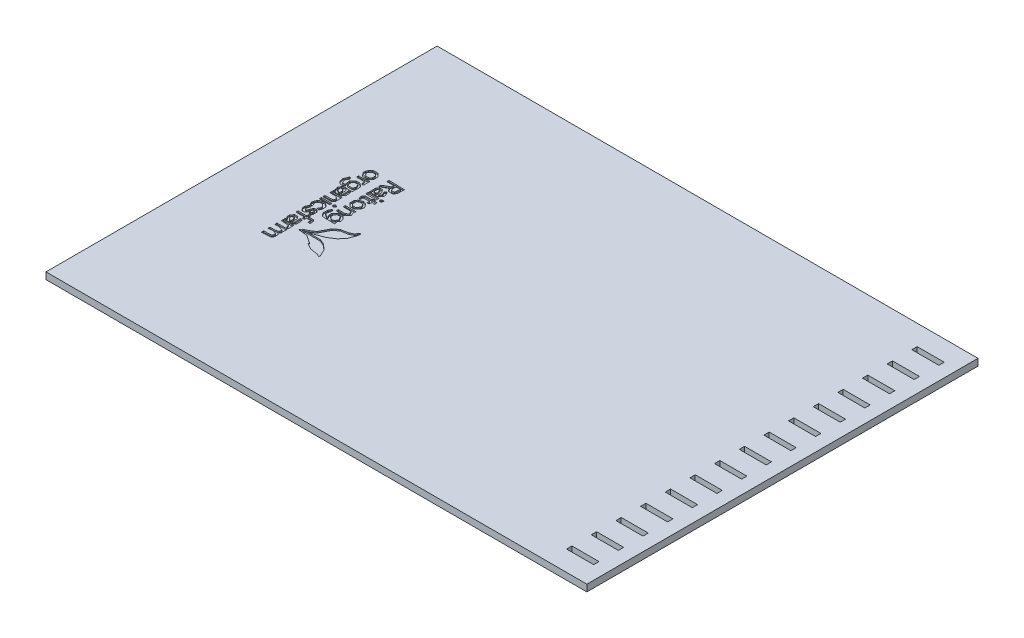
from build123d import *

# Parameters (mm, degrees)
SKETCH1_W           = 203.2
SKETCH1_H           = 146.939
BOSS_EXTRUDE1_DEPTH = 2.54
SKETCH2_W           = 2
SKETCH2_H           = 10.16
CUT_EXTRUDE1_DEPTH  = 2.794
LPATTERN1_COUNT     = 15
LPATTERN1_PITCH     = 9.264214286
CUT_EXTRUDE2_DEPTH  = 0.508


with BuildPart() as part:
    # Sketch1 → Boss-Extrude1 (new body)
    with BuildSketch(Plane(origin=(0, 0, 0), x_dir=(1, 0, 0), z_dir=(0, 1, 0))):
        with Locations((35.207920792, -46.991886139)):
            Rectangle(SKETCH1_W, SKETCH1_H)
    extrude(amount=BOSS_EXTRUDE1_DEPTH)

    # Sketch2 → Cut-Extrude1 (cut)
    with BuildSketch(Plane(origin=(0, 2.54, 0), x_dir=(0, 0, -1), z_dir=(0, 1, 0))):
        with Locations((-111.841386139, -126.647920792)):
            Rectangle(SKETCH2_W, SKETCH2_H)
    cut_extrude1 = extrude(amount=-CUT_EXTRUDE1_DEPTH, mode=Mode.SUBTRACT)

    # LPattern1: Cut-Extrude1 ×15
    with Locations(*[(0, 0, -i * LPATTERN1_PITCH) for i in range(1, LPATTERN1_COUNT)]):
        add(cut_extrude1, mode=Mode.SUBTRACT)

    # Sketch6 → Cut-Extrude2 (cut)
    with BuildSketch(Plane(origin=(0, 2.54, 0), x_dir=(1, 0, 0), z_dir=(0, 1, 0))):
        Polygon((-40.838764807, -35.000952541), (-40.694137208, -35.662419339), (-40.204374408, -36.161529338), (-39.714611608, -36.660613939), (-38.568055608, -36.660613939), (-37.421525008, -36.660613939), (-37.998892407, -36.874202538), (-38.576234408, -37.087791139), (-38.872779408, -37.641866739), (-39.169324408, -38.195942339), (-38.971661608, -38.781259939), (-38.773998808, -39.366577539), (-38.841334208, -39.829619538), (-38.908695008, -40.292636139), (-37.495718408, -40.292636139), (-36.082741808, -40.292636139), (-35.494706408, -39.880749739), (-34.906671008, -39.468863339), (-34.906671008, -38.711765539), (-34.906671008, -37.954667739), (-35.067275208, -37.536151939), (-35.227879408, -37.117636139), (-35.580380608, -37.117636139), (-35.932907208, -37.117636139), (-35.882818408, -38.213646139), (-35.832704208, -39.309656139), (-36.163437608, -39.426318339), (-36.494171008, -39.542980539), (-36.494171008, -38.613772339), (-36.494171008, -37.684589539), (-36.909943608, -37.268816939), (-37.325716208, -36.853044339), (-36.144641608, -36.853044339), (-34.963541608, -36.853044339), (-34.941418208, -35.27979374), (-34.919269408, -33.706543139), (-35.610098604, -33.163135542), (-36.300953208, -32.619702539), (-37.012889808, -32.619702539), (-37.724851808, -32.619702539), (-38.330972008, -33.264913339), (-38.937117608, -33.910098739), (-38.827110208, -34.852413342), (-38.717102808, -35.794702539), (-39.198813808, -35.794702539), (-39.680524808, -35.794702539), (-39.976968208, -35.144081539), (-40.273411608, -34.493460539), (-39.880092608, -33.887314939), (-39.486773608, -33.281169339), (-39.600032208, -32.950435939), (-39.713265408, -32.619702539), (-39.968586208, -32.619702539), (-40.223881608, -32.619702539), (-40.603637008, -33.479619539), (-40.983392408, -34.339511139), align=None)
        Polygon((-38.346262808, -38.446843539), (-38.346262808, -37.942602739), (-38.041539008, -37.754287138), (-37.736815208, -37.565946139), (-37.380072208, -38.053803939), (-37.023329208, -38.541687139), (-37.023329208, -39.020273939), (-37.023329208, -39.498886139), (-37.173011408, -39.498886139), (-37.322719008, -39.498886139), (-37.834478208, -39.224997939), (-38.346262808, -38.951084339), align=None, mode=Mode.SUBTRACT)
        Polygon((-38.027442008, -34.867373939), (-38.105521608, -34.072303139), (-37.776109008, -33.742890539), (-37.446671008, -33.413452539), (-36.832448208, -33.413452539), (-36.218250808, -33.413452539), (-35.907507208, -34.095467939), (-35.596763608, -34.777483339), (-35.875858808, -35.219951339), (-36.154979408, -35.662419339), (-37.052183608, -35.662419339), (-37.949387808, -35.662419339), align=None, mode=Mode.SUBTRACT)
        Polygon((-39.119108608, -28.152248939), (-39.140012808, -28.579603939), (-38.591626808, -29.276732339), (-38.043266208, -29.973886139), (-37.004126808, -29.973886139), (-35.965012808, -29.973886139), (-35.435829208, -29.444702539), (-34.906671008, -28.915544339), (-34.906671008, -28.072696139), (-34.906671008, -27.229847939), (-35.481955609, -26.617504738), (-36.057240208, -26.005136139), (-37.028460008, -26.005136139), (-37.999654408, -26.005136139), (-38.403006408, -26.468152739), (-38.806358408, -26.931169339), (-38.952306808, -27.328044338), (-39.098229808, -27.724919339), align=None)
        Polygon((-38.346262808, -27.893499139), (-38.346262808, -27.630431339), (-37.930490208, -27.214658739), (-37.514717608, -26.798886139), (-36.925056608, -26.798886139), (-36.335421008, -26.798886139), (-36.017921008, -27.116386139), (-35.700421008, -27.433886139), (-35.700421008, -27.989511139), (-35.700421008, -28.545136139), (-36.017921008, -28.862636139), (-36.335421008, -29.180136139), (-37.066941008, -29.180136139), (-37.798461008, -29.180136139), (-38.072374609, -28.668351537), (-38.346262808, -28.156592339), align=None, mode=Mode.SUBTRACT)
        Polygon((-39.123248808, -47.652209939), (-39.140012808, -48.000342339), (-38.866124608, -48.512101539), (-38.592211008, -49.023886139), (-38.176362208, -49.023886139), (-37.760462608, -49.023886139), (-37.951089609, -48.560869537), (-38.141716608, -48.097827539), (-38.264525608, -47.674257139), (-38.387334608, -47.250686739), (-37.951038808, -46.814365538), (-37.514717608, -46.378044339), (-37.023329208, -46.378044339), (-36.531966208, -46.378044339), (-36.116193608, -46.793816939), (-35.700421008, -47.209589539), (-35.700421008, -47.666941939), (-35.700421008, -48.124294339), (-36.009259608, -48.433132939), (-36.318072808, -48.741946139), (-35.850255608, -48.921473339), (-35.382438408, -49.100975139), (-35.148606008, -48.731709939), (-34.914773608, -48.362419339), (-34.910735008, -47.521730139), (-34.906671008, -46.681040939), (-35.603824811, -46.132654936), (-36.300953208, -45.584294339), (-36.944132008, -45.584294339), (-37.587310808, -45.584294339), (-38.114005208, -45.866183539), (-38.640699608, -46.148047339), (-38.873592208, -46.726075139), (-39.106459408, -47.304077539), align=None)
        Polygon((-39.122105808, -50.883242339), (-39.140089008, -51.287381739), (-38.728202608, -51.875417139), (-38.316240008, -52.463452539), (-37.817079208, -52.463452539), (-37.317918408, -52.463452539), (-36.906057408, -51.875417139), (-36.494171008, -51.287381739), (-36.494171008, -50.817100739), (-36.494171008, -50.346794339), (-36.097296008, -50.346794339), (-35.700421008, -50.346794339), (-35.700421008, -50.728048339), (-35.700421008, -51.109327739), (-35.965012808, -51.272827539), (-36.229579208, -51.436352739), (-36.229579208, -51.693629339), (-36.229579208, -51.950905939), (-35.806008808, -52.113440539), (-35.382438408, -52.275975139), (-35.148606008, -51.906709939), (-34.914773608, -51.537419339), (-34.910735008, -50.850831939), (-34.906671008, -50.164219139), (-35.425999409, -49.694242938), (-35.945302408, -49.224292139), (-36.363970607, -49.384947138), (-36.782664208, -49.545602139), (-37.178777208, -50.493682539), (-37.574915608, -51.441762939), (-37.894447608, -51.328809139), (-38.213979608, -51.215880739), (-38.164754408, -50.847479139), (-38.115554608, -50.479077539), (-37.935468608, -49.883777738), (-37.755382608, -49.288452539), (-38.142681808, -49.288452539), (-38.529981008, -49.288452539), (-38.817102608, -49.883777739), (-39.104198808, -50.479077539), align=None)
        Polygon((-39.140089008, -56.740050539), (-39.140089008, -57.194735939), (-38.900338408, -57.342894139), (-38.660587808, -57.491077739), (-38.798916208, -58.019981939), (-38.937219208, -58.548886139), (-37.337755808, -58.548886139), (-35.738292408, -58.548886139), (-35.322519808, -58.133113539), (-34.906747208, -57.717340939), (-34.906747208, -56.964129339), (-34.906747208, -56.210917739), (-35.067351408, -55.792401939), (-35.227955608, -55.373886139), (-35.601310208, -55.373886139), (-35.974690208, -55.373886139), (-35.903748009, -56.469845326), (-35.832805808, -57.565829939), (-36.163513808, -57.682517539), (-36.494247208, -57.799230539), (-36.494247208, -56.870022339), (-36.494247208, -55.940839539), (-36.910019808, -55.525066939), (-37.325792408, -55.109294339), (-37.821067008, -55.109294339), (-38.316341608, -55.109294339), (-38.728202608, -55.697329738), (-39.140089008, -56.285365139), align=None)
        Polygon((-38.346339008, -56.808554339), (-38.346339008, -56.496997939), (-37.967904408, -56.182952339), (-37.589495208, -55.868881339), (-37.306463008, -56.397734739), (-37.023430808, -56.926588139), (-37.023430808, -57.340862139), (-37.023430808, -57.755136139), (-37.367372208, -57.755136139), (-37.711339008, -57.755136139), (-38.028839008, -57.437636139), (-38.346339008, -57.120136139), align=None, mode=Mode.SUBTRACT)
        Polygon((-38.875421008, -30.899919339), (-38.875421008, -31.296794339), (-37.425258808, -31.296794339), (-35.975096608, -31.296794339), (-35.809056808, -31.958261138), (-35.643042408, -32.619702539), (-35.284521408, -32.619702539), (-34.925975008, -32.619702539), (-34.950536807, -31.396286195), (-34.975098608, -30.172844339), (-36.329934607, -30.335658339), (-37.684796008, -30.498446939), (-38.280095808, -30.500758339), (-38.875421008, -30.503044339), align=None)
        Polygon((-38.875421008, -40.954077539), (-38.875421008, -41.350952539), (-37.735367408, -41.350952539), (-36.595313808, -41.350952539), (-36.119089207, -41.699186539), (-35.642890008, -42.047395139), (-35.740375208, -42.559078139), (-35.837860408, -43.070761139), (-37.356627998, -43.150110738), (-38.875421008, -43.229460339), (-38.875421008, -43.613127339), (-38.875421008, -43.996794339), (-37.306818608, -43.996794339), (-35.738216208, -43.996794339), (-35.327523608, -43.586101739), (-34.916805608, -43.175383739), (-34.946320408, -41.866293138), (-34.975809808, -40.557202539), (-36.925615408, -40.557202539), (-38.875421008, -40.557202539), align=None)
        Polygon((-38.875421008, -44.922827539), (-38.875421008, -45.319702539), (-36.891046008, -45.319702539), (-34.906671008, -45.319702539), (-34.906671008, -44.922827539), (-34.906671008, -44.525952539), (-36.891046008, -44.525952539), (-38.875421008, -44.525952539), align=None)
        Polygon((-38.875421008, -53.654077539), (-38.875421008, -54.050952539), (-37.287921008, -54.050952539), (-35.700421008, -54.050952539), (-35.700421008, -54.447827539), (-35.700421008, -54.844702539), (-35.303546008, -54.844702539), (-34.906671008, -54.844702539), (-34.906671008, -54.447827539), (-34.906671008, -54.050952539), (-34.112921008, -54.050952539), (-33.319171008, -54.050952539), (-33.319171008, -54.580136139), (-33.319171008, -55.109294339), (-32.922296008, -55.109294339), (-32.525421008, -55.109294339), (-32.525421008, -54.500761139), (-32.525421008, -53.892202539), (-32.842921008, -53.574702539), (-33.160421008, -53.257202539), (-34.033546008, -53.257202539), (-34.906671008, -53.257202539), (-34.906671008, -52.860327539), (-34.906671008, -52.463452539), (-35.303546008, -52.463452539), (-35.700421008, -52.463452539), (-35.700421008, -52.860327539), (-35.700421008, -53.257202539), (-37.287921008, -53.257202539), (-38.875421008, -53.257202539), align=None)
        Polygon((-38.875421008, -59.196509939), (-38.875421008, -59.579567339), (-37.486345808, -59.659526539), (-36.097296008, -59.739511139), (-35.836107808, -60.334810939), (-35.574945008, -60.930136139), (-35.257394208, -60.930136139), (-34.939843408, -60.930136139), (-34.954448408, -59.871794339), (-34.969053408, -58.813452539), (-36.922237208, -58.813452539), (-38.875421008, -58.813452539), align=None)
        Polygon((-38.875446408, -61.591602939), (-38.875421008, -61.988452539), (-37.966609008, -61.988452539), (-37.057797008, -61.988452539), (-36.379109008, -62.246491139), (-35.700421008, -62.504529739), (-35.700421008, -63.009380139), (-35.700421008, -63.514255939), (-36.295746208, -63.673767939), (-36.891046008, -63.833330739), (-37.883246208, -63.836937539), (-38.875421008, -63.840569739), (-38.875421008, -64.220807739), (-38.875421008, -64.601045739), (-38.015529408, -64.464012739), (-37.155637808, -64.326954339), (-36.409690608, -64.613364739), (-35.663718008, -64.899749739), (-35.748223808, -65.494643139), (-35.832704208, -66.089536539), (-37.354062608, -66.168886139), (-38.875421008, -66.248235739), (-38.875421008, -66.662712939), (-38.875421008, -67.077215539), (-38.337404361, -67.042955026), (-35.399608808, -66.855879939), (-35.157191209, -66.47272094), (-34.914773608, -66.089536539), (-34.910735008, -65.377549139), (-34.906671008, -64.665536339), (-35.184115208, -64.494086339), (-35.461534008, -64.322610939), (-35.192776608, -63.998786339), (-34.924019208, -63.674936339), (-34.948911208, -62.434832139), (-34.973803208, -61.194727939), (-36.924624808, -61.194727939), (-38.875446408, -61.194727939), align=None)
        Polygon((-34.112921008, -44.938448539), (-34.112921008, -45.319702539), (-33.731667008, -45.319702539), (-33.350387608, -45.319702539), (-33.168599808, -45.025545139), (-32.986786608, -44.731387739), (-33.338779808, -44.513836739), (-33.690773008, -44.296285739), (-33.901847008, -44.426740139), (-34.112921008, -44.557194539), align=None)
        Polygon((-33.565855808, -48.399249339), (-33.583762808, -49.229829339), (-33.078150408, -49.854466139), (-32.572512608, -50.479077539), (-30.129616796, -50.572981339), (-27.686695608, -50.666885139), (-27.846029808, -50.057589939), (-28.005364008, -49.448294739), (-27.722306408, -49.107223539), (-27.439248808, -48.766177739), (-27.604298008, -48.108597139), (-27.769321808, -47.451016539), (-28.345190608, -46.914543139), (-28.921034008, -46.378044339), (-29.676938008, -46.378044339), (-30.432816608, -46.378044339), (-31.082243808, -47.027471539), (-31.731671008, -47.676898739), (-31.731671008, -48.235495539), (-31.731671008, -48.794092339), (-31.457782808, -49.305851539), (-31.183894608, -49.817636139), (-31.398905608, -49.817636139), (-31.613942008, -49.817636139), (-32.227199608, -49.388071339), (-32.840482608, -48.958531939), (-32.701646207, -48.263587935), (-32.562809808, -47.568669339), (-32.477973808, -47.067984539), (-32.393137808, -46.567299739), (-32.680107008, -46.465217139), (-32.967076208, -46.363134539), (-33.257499808, -46.965901939), (-33.547948808, -47.568669339), align=None)
        Polygon((-30.929869208, -48.519848539), (-30.921842808, -48.097827539), (-30.652145608, -47.634810939), (-30.382473808, -47.171794339), (-29.740260208, -47.171794339), (-29.098046608, -47.171794339), (-28.676254208, -47.815506538), (-28.254487208, -48.459218739), (-28.537595609, -48.98822454), (-28.820704008, -49.517204939), (-29.369115407, -49.691271138), (-29.917501408, -49.865311939), (-30.427711208, -49.403590739), (-30.937921008, -48.941869539), align=None, mode=Mode.SUBTRACT)
        Polygon((-31.066267208, -59.389575339), (-29.295430008, -59.568797739), (-27.867721408, -60.516751139), (-26.440012808, -61.464704539), (-26.440012808, -61.715427939), (-26.440012808, -61.966151339), (-25.315529408, -62.623554139), (-24.191046008, -63.280956939), (-22.510937609, -63.550298539), (-20.830854608, -63.819665539), (-20.460421008, -64.127081739), (-20.090012808, -64.434497939), (-20.092603608, -64.071379539), (-20.095194408, -63.708261139), (-20.717215008, -62.385327538), (-21.339261008, -61.062419339), (-22.316526008, -60.182995139), (-23.293816408, -59.303596339), (-24.271614806, -58.876165139), (-25.249387808, -58.448733939), (-27.970515208, -58.432655739), (-30.691642608, -58.416577539), (-29.702973008, -58.211142339), (-28.714328808, -58.005732539), (-26.849562408, -57.334562939), (-24.984821408, -56.663367939), (-23.721400008, -55.854479539), (-22.458004008, -55.045591139), (-21.570096208, -54.008280539), (-20.682213808, -52.970969939), (-20.121534207, -51.433279337), (-19.560829208, -49.895588739), (-19.560829208, -49.459724739), (-19.560829208, -49.023886139), (-19.816124608, -49.023886139), (-20.071394608, -49.023886139), (-20.353131408, -49.550301139), (-20.634868208, -50.076741539), (-21.420922008, -50.483217739), (-22.207001208, -50.889719339), (-23.57260681, -51.148697739), (-24.938187008, -51.407676139), (-25.809127608, -52.071962339), (-26.680042808, -52.736248539), (-27.664800807, -54.610235138), (-28.649533408, -56.484196339), (-29.674296408, -57.131108939), (-30.699059408, -57.777996139), (-31.413815407, -58.068267338), (-32.128546008, -58.358538539), (-31.467079209, -58.559630338), (-30.805637808, -58.760722139), (-31.621435008, -58.787087339), (-32.437232208, -58.813477939), (-32.637155609, -59.011902739), (-32.837104408, -59.210352939), align=None)
        Polygon((-31.731671008, -26.657916139), (-31.731671008, -27.063452539), (-30.389357208, -27.063452539), (-29.047043408, -27.063452539), (-29.135537008, -27.522938539), (-29.224005208, -27.982424539), (-30.365735208, -28.612242939), (-31.507465208, -29.242035939), (-31.652245208, -29.619378338), (-31.797050608, -29.996695339), (-31.672311208, -30.121434738), (-31.547546408, -30.246174139), (-30.298450607, -29.548055138), (-29.049354808, -28.849910739), (-28.655705608, -29.411885739), (-28.262081808, -29.973886139), (-27.360356408, -29.973886139), (-26.458631008, -29.973886139), (-26.158758608, -29.413562139), (-25.858886208, -28.853263539), (-25.818703408, -27.627637338), (-25.778546008, -26.402011139), (-28.755095807, -26.327182739), (-31.731671008, -26.252379739), align=None)
        Polygon((-28.288040608, -27.791060939), (-28.292079208, -27.063452539), (-27.482378008, -27.063452539), (-26.672651408, -27.063452539), (-26.754769608, -28.053442939), (-26.836887808, -29.043433339), (-27.334346808, -29.137819739), (-27.831805808, -29.232206139), (-28.057891208, -28.875437739), (-28.283976608, -28.518669339), align=None, mode=Mode.SUBTRACT)
        Polygon((-31.691285008, -32.40222774), (-31.662532208, -33.678044339), (-30.109601608, -33.678044339), (-28.556671008, -33.678044339), (-28.027512808, -33.148886139), (-27.498329208, -32.619702539), (-27.498329208, -32.235273539), (-27.498329208, -31.850869939), (-27.805389808, -31.176957139), (-28.112450408, -30.503044339), (-28.318952408, -30.503044339), (-28.525429008, -30.503044339), (-28.685576008, -30.762149739), (-28.845723008, -31.021280539), (-28.569853608, -31.536748139), (-28.293984208, -32.052215739), (-28.453623208, -32.468242339), (-28.613287608, -32.884294339), (-28.849558408, -32.884294339), (-29.085829208, -32.884294339), (-29.085829208, -32.281704739), (-29.085829208, -31.679115139), (-29.497715608, -31.091079739), (-29.909602008, -30.503044339), (-30.503123808, -30.503044339), (-31.096671008, -30.503044339), (-31.408354408, -30.814727739), (-31.720012408, -31.126385739), align=None)
        Polygon((-30.937921008, -31.966566939), (-30.937921008, -31.296794339), (-30.546075208, -31.296794339), (-30.154254808, -31.296794339), (-29.985141608, -31.970580139), (-29.816028408, -32.644365939), (-29.968682408, -32.797019939), (-30.121336408, -32.949673939), (-30.529641408, -32.792981339), (-30.937921008, -32.636314139), align=None, mode=Mode.SUBTRACT)
        Polygon((-31.731671008, -34.471794339), (-31.731671008, -35.000952539), (-30.020193608, -35.000952539), (-28.308690808, -35.000952539), (-28.460989208, -35.397827539), (-28.613287608, -35.794702539), (-29.875489808, -35.794702539), (-31.137717408, -35.794702539), (-31.455014208, -36.177023339), (-31.772285608, -36.559344139), (-31.685824008, -37.148497139), (-31.599387808, -37.737624739), (-31.268654408, -37.846565339), (-30.937921008, -37.955480539), (-30.937921008, -37.430894339), (-30.937921008, -36.906333539), (-29.747296008, -36.811642339), (-28.556671008, -36.716951139), (-28.556671008, -37.181872739), (-28.556671008, -37.646794339), (-28.159796008, -37.646794339), (-27.762921008, -37.646794339), (-27.762921008, -37.142401139), (-27.762921008, -36.638007939), (-27.233762807, -36.776387139), (-26.704579208, -36.914766339), (-26.704579208, -36.354747139), (-26.704579208, -35.794702539), (-27.233762808, -35.794702539), (-27.762921008, -35.794702539), (-27.762921008, -34.868669339), (-27.762921008, -33.942636139), (-29.747296008, -33.942636139), (-31.731671008, -33.942636139), align=None)
        Polygon((-31.731671008, -40.127713939), (-31.731671008, -40.919990739), (-31.156386408, -41.532333938), (-30.581101808, -42.144702539), (-29.701169608, -42.144702539), (-28.821262808, -42.144702539), (-28.298810208, -41.622275339), (-27.776383008, -41.099848139), (-27.608184208, -40.42971994), (-27.440010808, -39.759617139), (-27.879888008, -39.088269739), (-28.319765208, -38.416922339), (-28.967389008, -38.170694739), (-29.615012808, -37.924467139), (-30.342595807, -38.194418338), (-31.070204208, -38.464369539), (-31.400937608, -38.899903339), (-31.731671008, -39.335437139), align=None)
        Polygon((-30.937921008, -39.966601739), (-30.937921008, -39.217250939), (-30.352476408, -39.000665139), (-29.767031808, -38.784104739), (-29.285752607, -38.909961739), (-28.804498808, -39.035818739), (-28.529493008, -39.549660738), (-28.254487208, -40.063528139), (-28.676254208, -40.707240338), (-29.098046608, -41.350952539), (-29.700483808, -41.350952539), (-30.302921008, -41.350952539), (-30.620421008, -41.033452539), (-30.937921008, -40.715952539), align=None, mode=Mode.SUBTRACT)
        Polygon((-31.731671008, -43.070761139), (-31.731671008, -43.467636139), (-30.285776008, -43.467636139), (-28.839881008, -43.467636139), (-28.532490208, -44.041980939), (-28.225099408, -44.616351139), (-28.706023008, -44.968039539), (-29.186972008, -45.319702539), (-30.459334208, -45.319702539), (-31.731671008, -45.319702539), (-31.731671008, -45.716577539), (-31.731671008, -46.113452539), (-30.291211608, -46.113452539), (-28.850752208, -46.113452539), (-28.134497609, -45.49735014), (-27.418217608, -44.881222339), (-27.633660408, -44.108274939), (-27.849128608, -43.335327539), (-27.794417008, -43.004619539), (-27.739730808, -42.673886139), (-29.735688208, -42.673886139), (-31.731671008, -42.673886139), align=None)
        Polygon((-26.886494008, -34.587542139), (-26.792793408, -34.868669339), (-26.421572408, -34.868669339), (-26.050376808, -34.868669339), (-25.961197408, -34.405652738), (-25.872043408, -33.942636139), (-26.244204208, -33.942636139), (-26.616390408, -33.942636139), (-26.798305208, -34.124525539), (-26.980194608, -34.306440339), align=None)
    extrude(amount=-CUT_EXTRUDE2_DEPTH, mode=Mode.SUBTRACT)


solid = part.part
